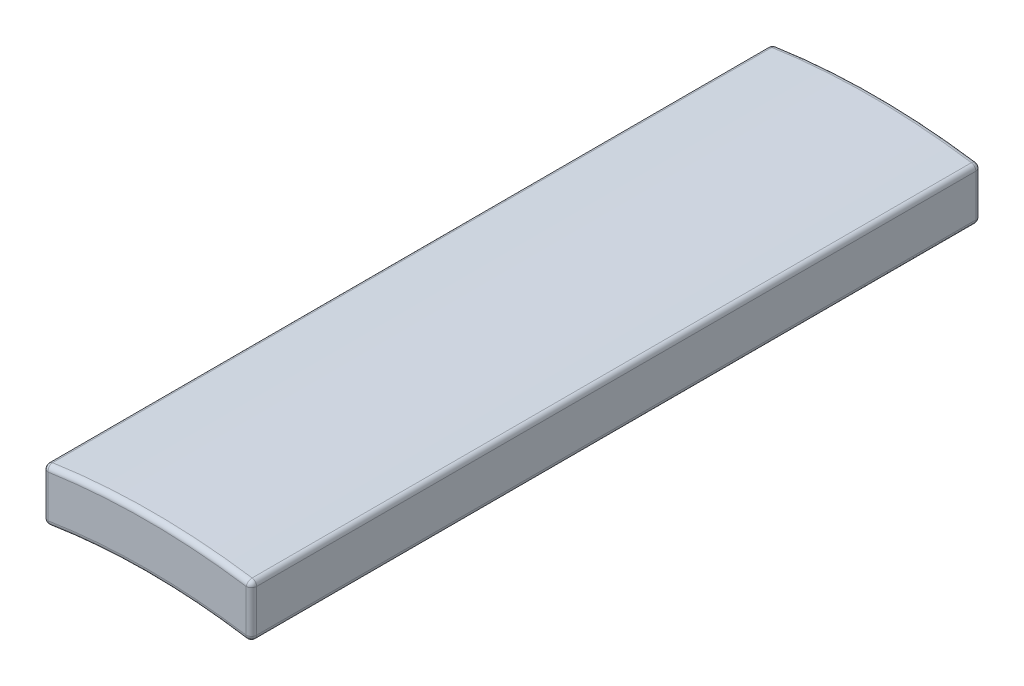
from build123d import *

# Parameters (mm, degrees)
BOSS_EXTRUDE1_DEPTH = 14
FILLET1_R           = 0.1


with BuildPart() as part:
    # Sketch1 → Boss-Extrude1 (new body)
    with BuildSketch(Plane.XY):
        with BuildLine():
            Line((2, 11.832159566), (2, 12.845232579))
            ThreePointArc((2, 12.845232579), (0, 13), (-2, 12.845232579))
            Line((-2, 12.845232579), (-2, 11.832159566))
            ThreePointArc((-2, 11.832159566), (0, 12), (2, 11.832159566))
        make_face()
    extrude(amount=BOSS_EXTRUDE1_DEPTH)

    # Fillet1
    fillet1_edges = [part.edges().sort_by_distance(p)[0] for p in [
        (0, 13, 14),
        (-2, 12.338696072, 14),
        (0, 12, 14),
        (-2, 12.338696072, 0),
        (0, 13, 0),
        (2, 12.338696072, 0),
        (0, 12, 0),
        (2, 12.338696072, 14),
        (-2, 11.832159566, 7),
        (-2, 12.845232579, 7),
        (2, 12.845232579, 7),
        (2, 11.832159566, 7),
    ]]
    fillet(fillet1_edges, radius=FILLET1_R)


solid = part.part
